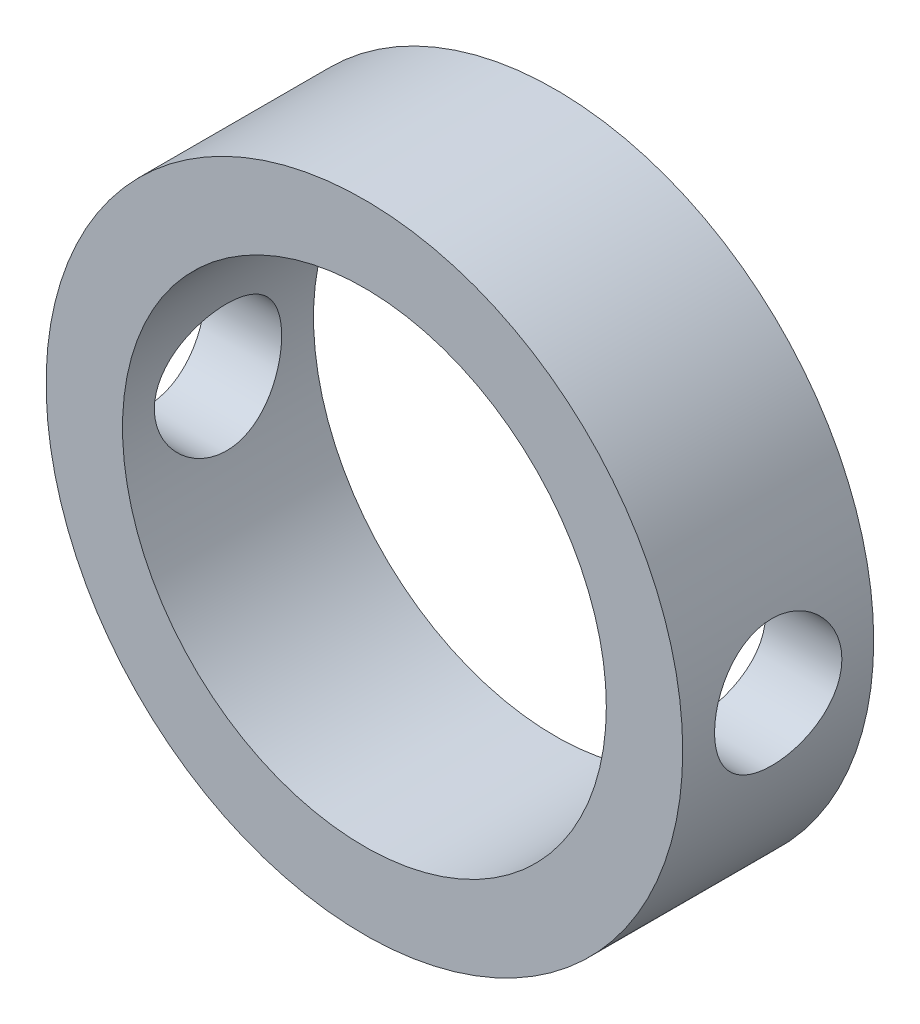
from build123d import *

# Parameters (mm, degrees)
ESBO_O1_R                  = 10
ESBO_O1_R_2                = 7.6
RESSALTO_EXTRUS_O1_DEPTH   = 6
ESBO_O2_R                  = 2
CORTE_EXTRUS_O1_DEPTH      = 11
CORTE_EXTRUS_O1_DEPTH_BACK = 11


with BuildPart() as part:
    # Esboço1 → Ressalto-extrusão1 (new body)
    with BuildSketch(Plane.XY):
        Circle(ESBO_O1_R)
        Circle(ESBO_O1_R_2, mode=Mode.SUBTRACT)
    extrude(amount=RESSALTO_EXTRUS_O1_DEPTH)

    # Esboço2 → Corte-extrusão1 (cut, two sides)
    with BuildSketch(Plane(origin=(0, 0, 0), x_dir=(0, 0, -1), z_dir=(1, 0, 0))) as corte_extrus_o1_sk:
        with Locations((-3, 0)):
            Circle(ESBO_O2_R)
    extrude(amount=CORTE_EXTRUS_O1_DEPTH, mode=Mode.SUBTRACT)
    extrude(corte_extrus_o1_sk.sketch, amount=-CORTE_EXTRUS_O1_DEPTH_BACK, mode=Mode.SUBTRACT)


solid = part.part
